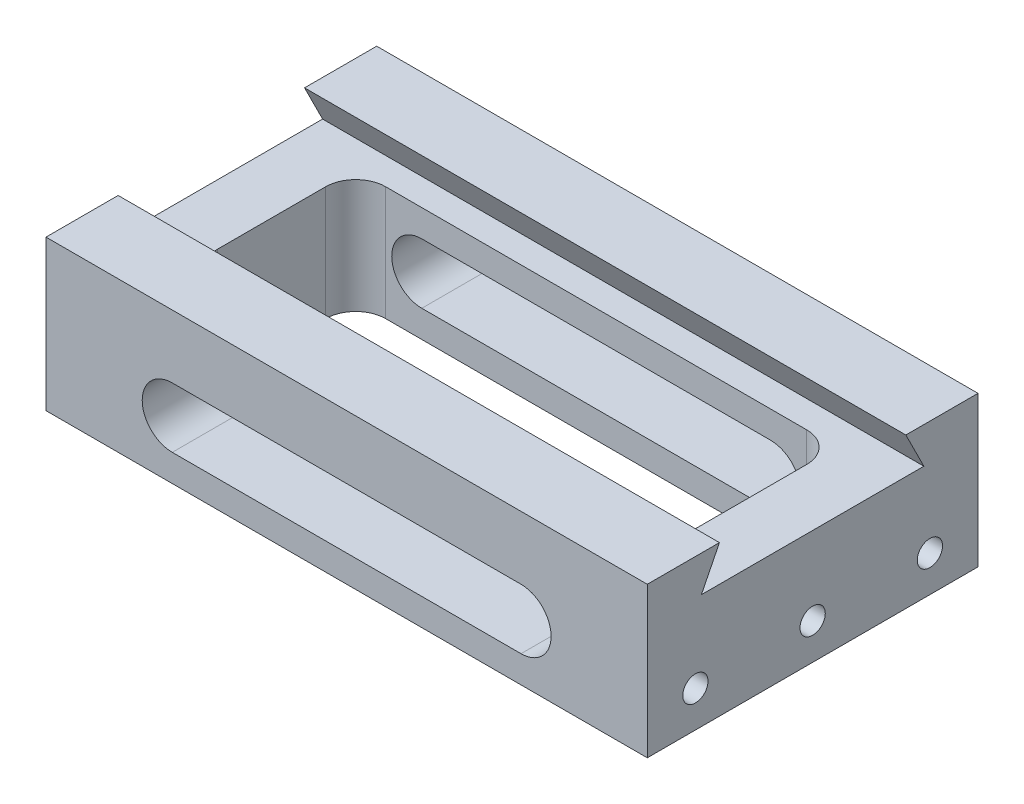
from build123d import *

# Parameters (mm, degrees)
SKETCH1_W                      = 100
SKETCH1_H                      = 55
BOSS_EXTRUDE1_DEPTH            = 25
CUT_EXTRUDE1_DEPTH             = 26
CUT_EXTRUDE2_DEPTH             = 101
CUT_EXTRUDE3_DEPTH             = 56
M5X0_8_TAPPED_HOLE1_AT_2_COUNT = 2
M5X0_8_TAPPED_HOLE1_AT_2_PITCH = 19.5
M5X0_8_TAPPED_HOLE1_AT_3_COUNT = 2
M5X0_8_TAPPED_HOLE1_AT_3_PITCH = 39


with BuildPart() as part:
    # Sketch1 → Boss-Extrude1 (new body)
    with BuildSketch(Plane(origin=(0, 0, 0), x_dir=(1, 0, 0), z_dir=(0, 1, 0))):
        Rectangle(SKETCH1_W, SKETCH1_H)
    extrude(amount=BOSS_EXTRUDE1_DEPTH)

    # Sketch2 → Cut-Extrude1 (cut, through all)
    with BuildSketch(Plane(origin=(0, 25, 0), x_dir=(1, 0, 0), z_dir=(0, 1, 0))):
        with BuildLine():
            Line((-35, -14), (35, -14))
            ThreePointArc((35, -14), (38.535533906, -12.535533906), (40, -9))
            Line((40, -9), (40, 9))
            ThreePointArc((40, 9), (38.535533906, 12.535533906), (35, 14))
            Line((35, 14), (-35, 14))
            ThreePointArc((-35, 14), (-38.535533906, 12.535533906), (-40, 9))
            Line((-40, 9), (-40, -9))
            ThreePointArc((-40, -9), (-38.535533906, -12.535533906), (-35, -14))
        make_face()
    extrude(amount=-CUT_EXTRUDE1_DEPTH, mode=Mode.SUBTRACT)

    # Sketch3 → Cut-Extrude2 (cut, through all)
    with BuildSketch(Plane(origin=(50, 0, 0), x_dir=(0, 0, -1), z_dir=(1, 0, 0))):
        Polygon((15.5, 25), (18.5, 19), (-18.5, 19), (-15.5, 25), align=None)
    extrude(amount=-CUT_EXTRUDE2_DEPTH, mode=Mode.SUBTRACT)

    # Sketch4 → Cut-Extrude3 (cut, through all)
    with BuildSketch(Plane.XY.offset(27.5)):
        with BuildLine():
            Line((-29, 14.5), (29, 14.5))
            ThreePointArc((29, 14.5), (34, 9.5), (29, 4.5))
            Line((29, 4.5), (-29, 4.5))
            ThreePointArc((-29, 4.5), (-34, 9.5), (-29, 14.5))
        make_face()
    extrude(amount=-CUT_EXTRUDE3_DEPTH, mode=Mode.SUBTRACT)

    # Sketch7 → M5x0.8 Tapped Hole1 (revolve, cut)
    with BuildSketch(Plane(origin=(50, 6, 19.5), x_dir=(0, 0, -1), z_dir=(0, 1, 0))):
        Polygon((0, 0), (0, 8.7618073), (2.1, 7.5), (2.1, 0), align=None)
    m5x0_8_tapped_hole1 = revolve(axis=Axis((56.35, 6, 19.5), (-1, 0, 0)), mode=Mode.SUBTRACT)

    # M5x0.8 Tapped Hole1 at 2: M5x0.8 Tapped Hole1 ×2
    with Locations(*[(0, 0, -i * M5X0_8_TAPPED_HOLE1_AT_2_PITCH) for i in range(1, M5X0_8_TAPPED_HOLE1_AT_2_COUNT)]):
        add(m5x0_8_tapped_hole1, mode=Mode.SUBTRACT)

    # M5x0.8 Tapped Hole1 at 3: M5x0.8 Tapped Hole1 ×2
    with Locations(*[(0, 0, -i * M5X0_8_TAPPED_HOLE1_AT_3_PITCH) for i in range(1, M5X0_8_TAPPED_HOLE1_AT_3_COUNT)]):
        add(m5x0_8_tapped_hole1, mode=Mode.SUBTRACT)

    # Mirror1: M5x0.8 Tapped Hole1 across plane
    add(m5x0_8_tapped_hole1.mirror(Plane(origin=(0, 0, 0), x_dir=(0, 0, 1), z_dir=(1, 0, 0))), mode=Mode.SUBTRACT)

    # Mirror1 copy 1 sketch → Mirror1 copy 1 (revolve, cut)
    with BuildSketch(Plane(origin=(-50, 6, 0), x_dir=(0, 0, -1), z_dir=(0, 1, 0))):
        Polygon((0, 0), (0, -8.7618073), (2.1, -7.5), (2.1, 0), align=None)
    revolve(axis=Axis((-56.35, 6, 0), (-1, 0, 0)), mode=Mode.SUBTRACT)

    # Mirror1 copy 2 sketch → Mirror1 copy 2 (revolve, cut)
    with BuildSketch(Plane(origin=(-50, 6, -19.5), x_dir=(0, 0, -1), z_dir=(0, 1, 0))):
        Polygon((0, 0), (0, -8.7618073), (2.1, -7.5), (2.1, 0), align=None)
    revolve(axis=Axis((-56.35, 6, -19.5), (-1, 0, 0)), mode=Mode.SUBTRACT)


solid = part.part
